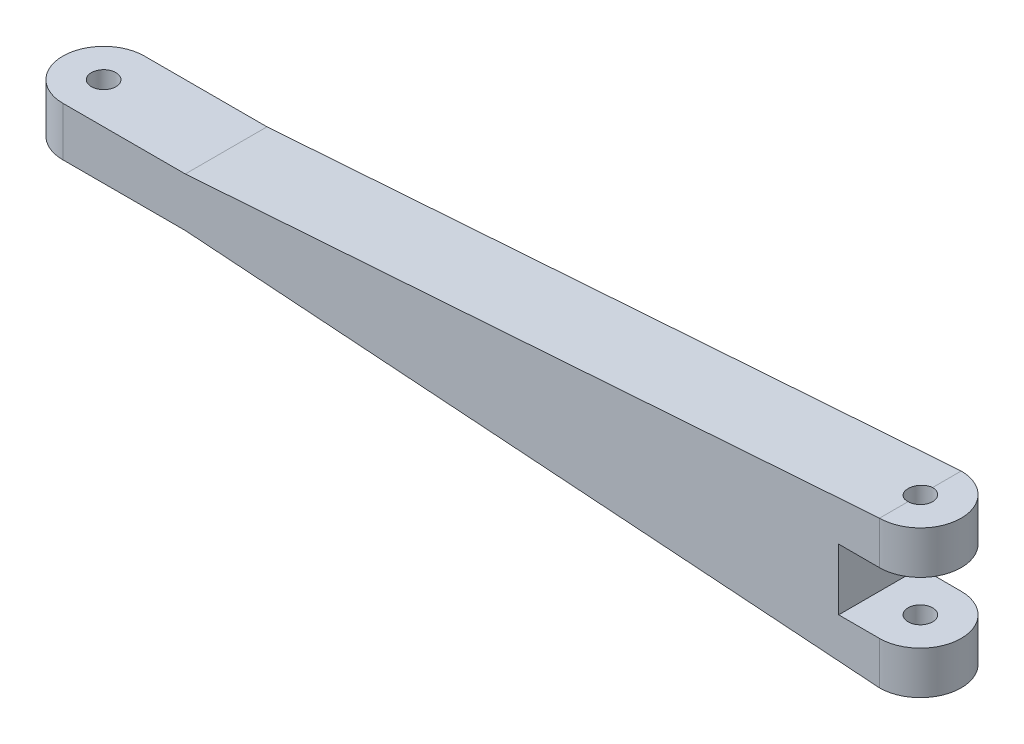
from build123d import *

# Parameters (mm, degrees)
BOSS_EXTRUDE2_DEPTH     = 4.5
CUT_EXTRUDE3_DEPTH      = 3.5
CUT_EXTRUDE3_DEPTH_BACK = 3.5
SKETCH4_R               = 2.5
CUT_EXTRUDE4_DEPTH      = 1.875
SKETCH6_R               = 0.75
CUT_EXTRUDE6_DEPTH      = 5.5
CUT_EXTRUDE6_DEPTH_BACK = 5.5
SKETCH8_W               = 5
SKETCH8_H               = 3.75
CUT_EXTRUDE10_DEPTH     = 20


with BuildPart() as part:
    # Sketch2 → Boss-Extrude2 (new body, symmetric)
    with BuildSketch(Plane(origin=(0, 0, 0), x_dir=(1, 0, 0), z_dir=(0, 1, 0))):
        with BuildLine():
            Line((-50, 2.5), (0, 2.5))
            ThreePointArc((0, 2.5), (2.5, 0), (0, -2.5))
            Line((0, -2.5), (-50, -2.5))
            ThreePointArc((-50, -2.5), (-52.5, 0), (-50, 2.5))
        make_face()
    extrude(amount=BOSS_EXTRUDE2_DEPTH, both=True)

    # Sketch3 → Cut-Extrude3 (cut, two sides)
    with BuildSketch(Plane.XY) as cut_extrude3_sk:
        Polygon((-52.5, -1.5), (-42.5, -1.5), (0, -4.5), (-52.5, -4.5), align=None)
        Polygon((-52.5, 1.5), (-42.5, 1.5), (0, 4.5), (-52.5, 4.5), align=None)
    extrude(amount=CUT_EXTRUDE3_DEPTH, mode=Mode.SUBTRACT)
    extrude(cut_extrude3_sk.sketch, amount=-CUT_EXTRUDE3_DEPTH_BACK, mode=Mode.SUBTRACT)

    # Sketch4 → Cut-Extrude4 (cut, symmetric)
    with BuildSketch(Plane(origin=(0, 0, 0), x_dir=(1, 0, 0), z_dir=(0, 1, 0))):
        Circle(SKETCH4_R)
    extrude(amount=CUT_EXTRUDE4_DEPTH, both=True, mode=Mode.SUBTRACT)

    # Sketch6 → Cut-Extrude6 (cut, two sides)
    with BuildSketch(Plane(origin=(0, 0, 0), x_dir=(1, 0, 0), z_dir=(0, 1, 0))) as cut_extrude6_sk:
        with Locations(Location((-50, 0, 0), (0, 0, 90))):  # turned: the seam where the file's is
            Circle(SKETCH6_R)
        with Locations(Location((0, 0, 0), (0, 0, 270))):  # turned: the seam where the file's is
            Circle(SKETCH6_R)
    extrude(amount=CUT_EXTRUDE6_DEPTH, mode=Mode.SUBTRACT)
    extrude(cut_extrude6_sk.sketch, amount=-CUT_EXTRUDE6_DEPTH_BACK, mode=Mode.SUBTRACT)

    # Sketch8 → Cut-Extrude10 (cut, symmetric)
    with BuildSketch(Plane.XY):
        Rectangle(SKETCH8_W, SKETCH8_H)
    extrude(amount=CUT_EXTRUDE10_DEPTH, both=True, mode=Mode.SUBTRACT)


solid = part.part
